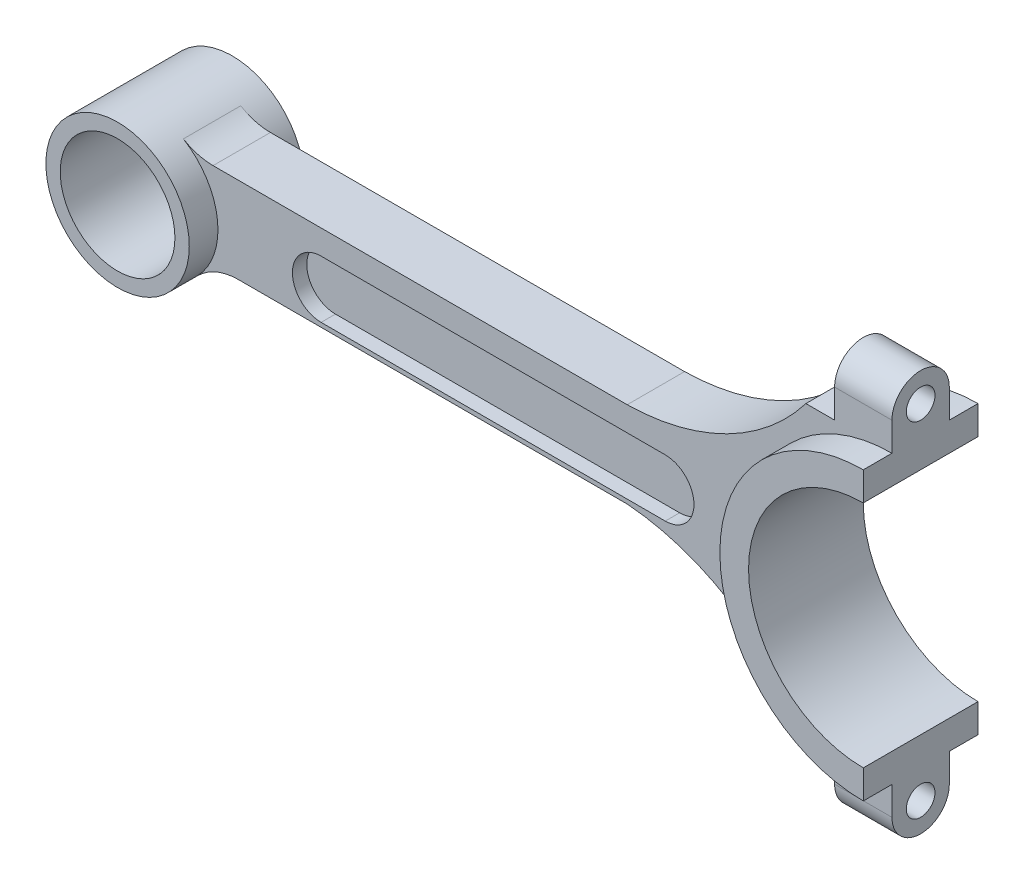
from build123d import *

# Parameters (mm, degrees)
BOSS_EXTRUDE2_DEPTH = 6.35
SKETCH2_8_R         = 15.875
SKETCH2_8_R_2       = 12.7
BOSS_EXTRUDE3_DEPTH = 12.7
BOSS_EXTRUDE4_DEPTH = 3.175
SKETCH3_R           = 3.175
BOSS_EXTRUDE6_DEPTH = 12.7


with BuildPart() as part:
    # Sketch2 → Boss-Extrude2 (new, symmetric)
    with BuildSketch(Plane.XY):
        with BuildLine():
            Line((106.485681071, 11.7475), (14.793592152, 11.7475))
            ThreePointArc((14.793592152, 11.7475), (11.380569705, 12.214704826), (8.218662306, 13.581944444))
            ThreePointArc((8.218662306, 13.581944444), (13.829079671, 7.79565138), (15.875, 0))
            ThreePointArc((15.875, 0), (14.696781618, -6.001686018), (11.33701763, -11.1125))
            ThreePointArc((11.33701763, -11.1125), (15.487942885, -8.293678539), (20.406631735, -7.3025))
            Line((20.406631735, -7.3025), (106.48193654, -7.3025))
            ThreePointArc((106.48193654, -7.3025), (129.228859651, -14.730836392), (146.05, -31.75))
            Line((146.05, -31.75), (165.1, -31.75))
            ThreePointArc((165.1, -31.75), (133.35, 0), (165.1, 31.75))
            Line((165.1, 31.75), (146.05, 31.75))
            ThreePointArc((146.05, 31.75), (128.565457442, 17.204135674), (106.485681071, 11.7475))
        make_face()
        with BuildLine():
            ThreePointArc((38.712408675, -6.35), (32.362408675, 0), (38.712408675, 6.35))
            Line((38.712408675, 6.35), (114.912408675, 6.35))
            ThreePointArc((114.912408675, 6.35), (121.262408675, 0), (114.912408675, -6.35))
            Line((114.912408675, -6.35), (38.712408675, -6.35))
        make_face(mode=Mode.SUBTRACT)
    extrude(amount=BOSS_EXTRUDE2_DEPTH, both=True)

    # Sketch2_8 → Boss-Extrude3 (add, symmetric)
    # profile 1 of 2: a face of its own
    with BuildSketch(Plane.XY):
        Circle(SKETCH2_8_R)
        Circle(SKETCH2_8_R_2, mode=Mode.SUBTRACT)
    # profile 2 of 2: a face of its own
    with BuildSketch(Plane.XY):
        with BuildLine():
            Line((165.1, 25.4), (165.1, 31.75))
            ThreePointArc((165.1, 31.75), (133.35, 0), (165.1, -31.75))
            Line((165.1, -31.75), (165.1, -25.4))
            ThreePointArc((165.1, -25.4), (139.7, 0), (165.1, 25.4))
        make_face()
    extrude(amount=BOSS_EXTRUDE3_DEPTH, both=True)

    # Sketch2_9 → Boss-Extrude4 (add, symmetric)
    with BuildSketch(Plane.XY):
        with BuildLine():
            Line((114.912408675, 6.35), (38.712408675, 6.35))
            ThreePointArc((38.712408675, 6.35), (32.362408675, 0), (38.712408675, -6.35))
            Line((38.712408675, -6.35), (114.912408675, -6.35))
            ThreePointArc((114.912408675, -6.35), (121.262408675, 0), (114.912408675, 6.35))
        make_face()
    extrude(amount=BOSS_EXTRUDE4_DEPTH, both=True)

    # Sketch3 → Boss-Extrude6 (add)
    # profile 1 of 2: a face of its own
    with BuildSketch(Plane(origin=(165.1, 0, 0), x_dir=(0, 0, -1), z_dir=(1, 0, 0))):
        with BuildLine():
            Line((-6.35, 38.085125464), (-6.35, 31.75))
            Line((-6.35, 31.75), (6.35, 31.75))
            Line((6.35, 31.75), (6.35, 38.085125464))
            ThreePointArc((6.35, 38.085125464), (0, 44.435125464), (-6.35, 38.085125464))
        make_face()
        with Locations((0, 38.085125464)):
            Circle(SKETCH3_R, mode=Mode.SUBTRACT)
    # profile 2 of 2: a face of its own
    with BuildSketch(Plane(origin=(165.1, 0, 0), x_dir=(0, 0, -1), z_dir=(1, 0, 0))):
        with BuildLine():
            Line((6.35, -31.75), (-6.35, -31.75))
            Line((-6.35, -31.75), (-6.35, -38.058434683))
            ThreePointArc((-6.35, -38.058434683), (0, -44.408434683), (6.35, -38.058434683))
            Line((6.35, -38.058434683), (6.35, -31.75))
        make_face()
        with Locations((0, -38.058434683)):
            Circle(SKETCH3_R, mode=Mode.SUBTRACT)
    extrude(amount=-BOSS_EXTRUDE6_DEPTH)


solid = part.part
